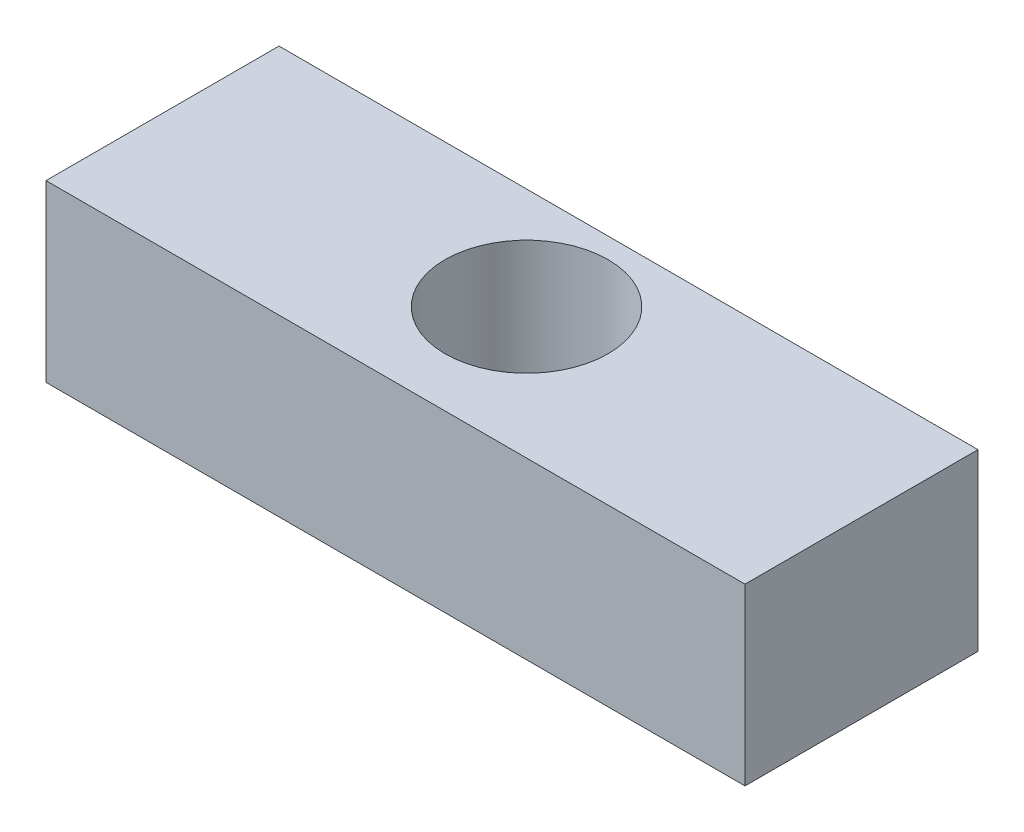
from build123d import *

# Parameters (mm, degrees)
SKETCH1_W           = 38.1
SKETCH1_H           = 12.7
SKETCH1_R           = 4.445
BOSS_EXTRUDE1_DEPTH = 9.525


with BuildPart() as part:
    # Sketch1 → Boss-Extrude1 (new body)
    with BuildSketch(Plane(origin=(0, 0, 0), x_dir=(1, 0, 0), z_dir=(0, 1, 0))):
        with Locations((19.05, 6.35)):
            Rectangle(SKETCH1_W, SKETCH1_H)
        with Locations((19.05, 7.14375)):
            Circle(SKETCH1_R, mode=Mode.SUBTRACT)
    extrude(amount=BOSS_EXTRUDE1_DEPTH)


solid = part.part
